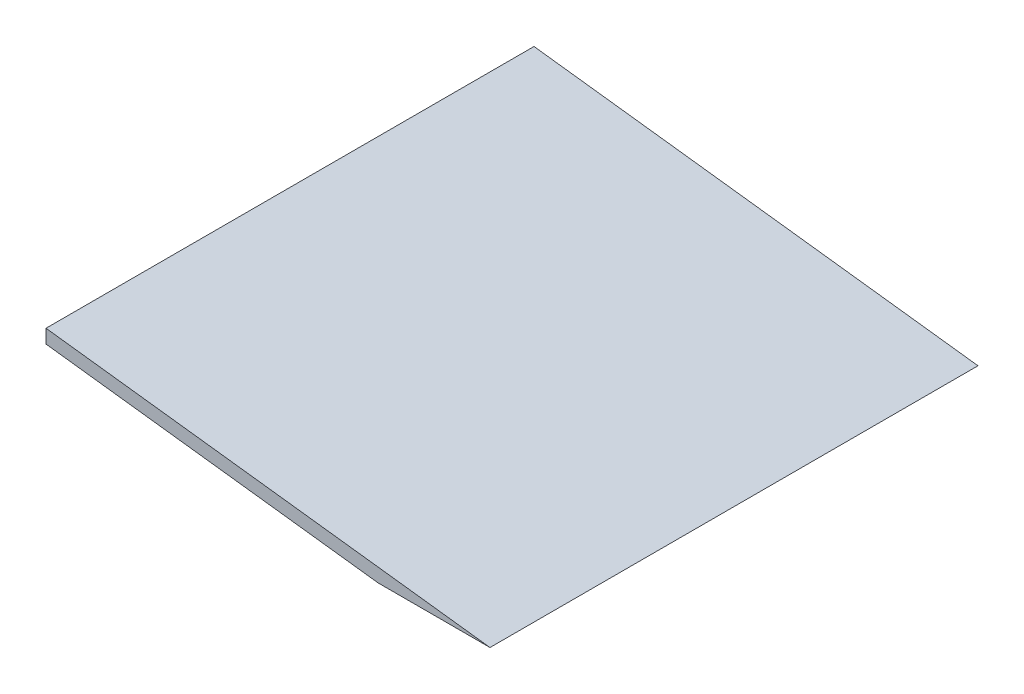
from build123d import *

# Parameters (mm, degrees)
BOSS_EXTRUDE1_DEPTH = 113.6904


with BuildPart() as part:
    # Sketch1 → Boss-Extrude1 (new body)
    with BuildSketch(Plane.XY):
        Polygon((0, 0), (103.433199635, -12.7), (77.380708407, -12.7), (0, -3.198843696), align=None)
    extrude(amount=BOSS_EXTRUDE1_DEPTH)


solid = part.part
